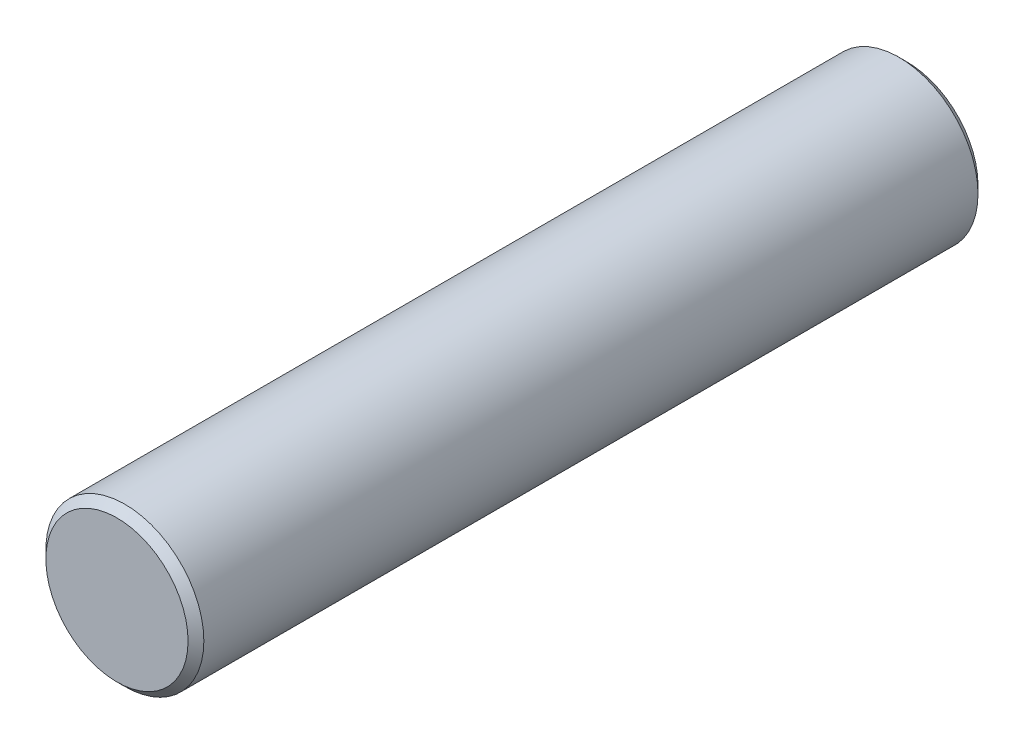
from build123d import *

# Parameters (mm, degrees)
ESQUISSE1_R          = 2.5
BASE_EXTRUSION_DEPTH = 25
CHANFREIN1_SIZE      = 0.25


with BuildPart() as part:
    # Esquisse1 → Base-Extrusion (new body)
    with BuildSketch(Plane.XY):
        Circle(ESQUISSE1_R)
    extrude(amount=BASE_EXTRUSION_DEPTH)

    # Chanfrein1
    chanfrein1_edges = [part.edges().sort_by_distance(p)[0] for p in [
        (-2.5, 0, 0),
        (-2.5, 0, 25),
    ]]
    chamfer(chanfrein1_edges, length=CHANFREIN1_SIZE)


solid = part.part
